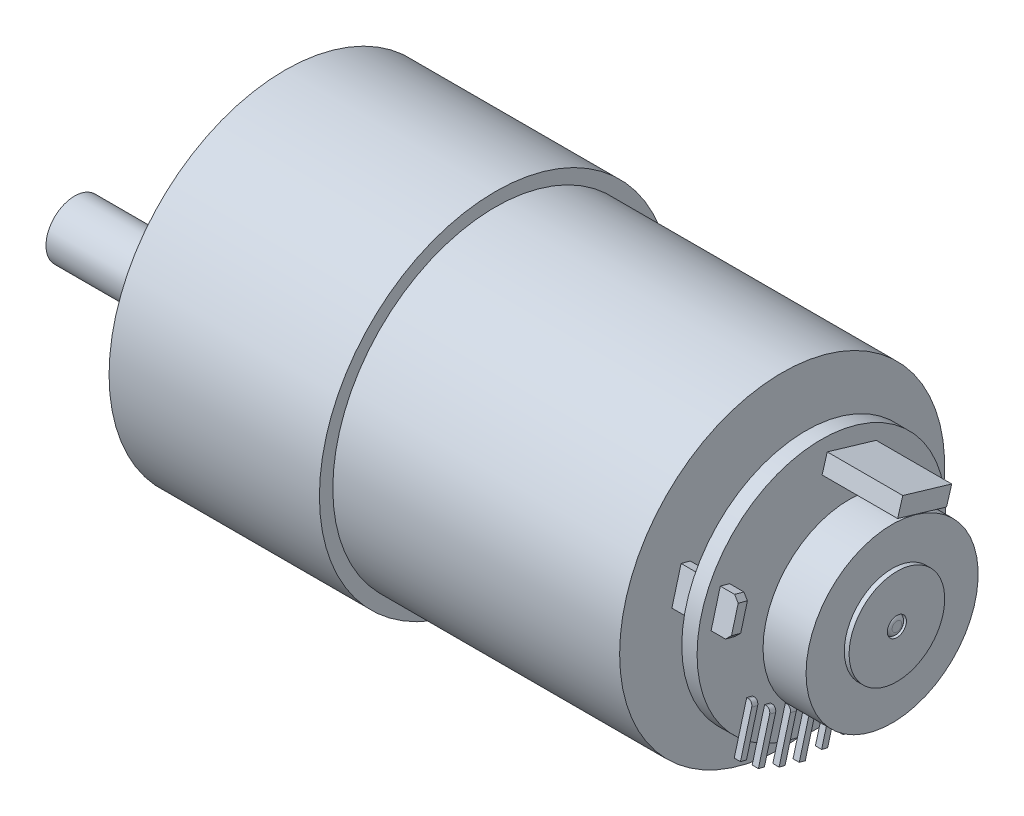
from build123d import *

# Parameters (mm, degrees)
SKETCH2_R           = 6
BOSS_EXTRUDE1_DEPTH = 6.5
SKETCH3_R           = 3
BOSS_EXTRUDE2_DEPTH = 15.5
CUT_EXTRUDE1_DEPTH  = 12
CHAMFER1_SIZE       = 1
SKETCH5_R           = 1.23
CUT_EXTRUDE2_DEPTH  = 5
CIRPATTERN1_COUNT   = 6
BOSS_EXTRUDE3_DEPTH = 7.9
BOSS_EXTRUDE4_DEPTH = 6.1
CHAMFER2_SIZE       = 0.5
BOSS_EXTRUDE5_DEPTH = 0.65
FILLET1_R           = 0.5
CUT_EXTRUDE3_DEPTH  = 1


with BuildPart() as part:
    # Sketch1 → Revolve1 (revolve)
    with BuildSketch(Plane.XY):
        with BuildLine():
            Line((0, 0), (64, 0))
            Line((64, 0), (64, 0.5))
            ThreePointArc((64, 0.5), (63.853553391, 0.853553391), (63.5, 1))
            Line((63.5, 1), (64, 1))
            Line((64, 1), (64, 5))
            Line((64, 5), (63.5, 5))
            Line((63.5, 5), (63.5, 9))
            Line((63.5, 9), (59, 9))
            Line((59, 9), (59, 1))
            Line((59, 1), (56.1, 1))
            Line((56.1, 1), (56.1, 13))
            Line((56.1, 13), (54.5, 13))
            Line((54.5, 13), (54.5, 1))
            Line((54.5, 1), (52, 1))
            Line((52, 1), (52, 17))
            Line((52, 17), (22, 17))
            Line((22, 17), (22, 18.4))
            Line((22, 18.4), (0, 18.4))
            Line((0, 18.4), (0, 0))
        make_face()
    revolve(axis=Axis((0, 0, 0), (1, 0, 0)))

    # Sketch2 → Boss-Extrude1 (add)
    with BuildSketch(Plane.ZY):
        with Locations((0, -7)):
            Circle(SKETCH2_R)
    extrude(amount=BOSS_EXTRUDE1_DEPTH)

    # Sketch3 → Boss-Extrude2 (add)
    with BuildSketch(Plane.ZY.offset(6.5)):
        with Locations((0, -7)):
            Circle(SKETCH3_R)
    extrude(amount=BOSS_EXTRUDE2_DEPTH)

    # Sketch4 → Cut-Extrude1 (cut)
    with BuildSketch(Plane.ZY.offset(22)):
        with BuildLine():
            Line((1.5, -9.598076211), (-1.5, -9.598076211))
            ThreePointArc((-1.5, -9.598076211), (0, -10), (1.5, -9.598076211))
        make_face()
    extrude(amount=-CUT_EXTRUDE1_DEPTH, mode=Mode.SUBTRACT)

    # Chamfer1
    chamfer1_edges = [part.edges().sort_by_distance(p)[0] for p in [
        (-6.5, -7, -6),
    ]]
    chamfer(chamfer1_edges, length=CHAMFER1_SIZE)

    # Sketch5 → Cut-Extrude2 (cut)
    with BuildSketch(Plane.ZY):
        with Locations((15.5, 0)):
            Circle(SKETCH5_R)
    cut_extrude2 = extrude(amount=-CUT_EXTRUDE2_DEPTH, mode=Mode.SUBTRACT)

    # CirPattern1: Cut-Extrude2 ×6 about axis
    cirpattern1_axis = Axis((0, 0, 0), (1, 0, 0))
    for i in range(1, CIRPATTERN1_COUNT):
        add(cut_extrude2.rotate(cirpattern1_axis, i * 360 / CIRPATTERN1_COUNT), mode=Mode.SUBTRACT)

    # Sketch6 → Boss-Extrude3 (add)
    with BuildSketch(Plane(origin=(56.1, 0, 0), x_dir=(0, 0, -1), z_dir=(1, 0, 0))):
        Polygon((0.614545099, 11.559081954), (5.734377326, 10.04515307), (5.196377764, 8.225736367), (0.076545537, 9.739665251), align=None)
    extrude(amount=BOSS_EXTRUDE3_DEPTH)

    # Sketch7 → Boss-Extrude4 (add)
    with BuildSketch(Plane(origin=(52, 0, 0), x_dir=(0, 0, -1), z_dir=(1, 0, 0))):
        Polygon((-10.569640254, 4.993749072), (-11.532445624, 1.431369202), (-10.567082231, 1.170460177), (-9.604276861, 4.732840047), align=None)
        Polygon((10.960206493, -0.825128427), (9.997401123, -4.387508297), (10.962764516, -4.648417322), (11.925569886, -1.086037452), align=None)
    extrude(amount=BOSS_EXTRUDE4_DEPTH)

    # Chamfer2
    chamfer2_edges = [part.edges().sort_by_distance(p)[0] for p in [
        (58.1, 1.300914689, 11.049763927),
        (58.1, 4.86329456, 10.086958557),
        (58.1, -4.51796281, -10.480082819),
        (58.1, -0.955582939, -11.44288819),
    ]]
    chamfer(chamfer2_edges, length=CHAMFER2_SIZE)

    # Sketch9 → Boss-Extrude5 (add)
    with BuildSketch(Plane(origin=(56.1, 0, 0), x_dir=(0, 0, -1), z_dir=(1, 0, 0))):
        Polygon((-7.807702145, -6.480963086), (-9.112247271, -11.307780051), (-8.484761066, -11.477370917), (-7.18021594, -6.650553952), align=None)
        Polygon((-5.932615753, -8.052596911), (-7.237160879, -12.879413876), (-6.609674674, -13.049004742), (-5.305129548, -8.222187777), align=None)
        Polygon((-3.769488931, -8.99589657), (-5.074034056, -13.822713535), (-4.446547851, -13.992304402), (-3.142002725, -9.165487437), align=None)
        Polygon((-1.65786261, -9.621868256), (-2.962407736, -14.448685221), (-2.33492153, -14.618276088), (-1.030376405, -9.791459122), align=None)
        Polygon((0.680101248, -9.624615249), (-0.624443878, -14.451432214), (0.003042327, -14.62102308), (1.307587453, -9.794206115), align=None)
        Polygon((2.920113487, -9.395250912), (1.615568361, -14.222067877), (2.243054567, -14.391658744), (3.547599693, -9.564841778), align=None)
    extrude(amount=BOSS_EXTRUDE5_DEPTH)

    # Fillet1
    fillet1_edges = [part.edges().sort_by_distance(p)[0] for p in [
        (56.75, -6.565758519, 7.493959043),
        (56.75, -8.137392344, 5.618872651),
        (56.75, -9.080692003, 3.455745828),
        (56.75, -9.706663689, 1.344119507),
        (56.75, -9.709410682, -0.99384435),
        (56.75, -9.480046345, -3.23385659),
    ]]
    fillet(fillet1_edges, radius=FILLET1_R)

    # Sketch14 → Cut-Extrude3 (cut)
    with BuildSketch(Plane.ZY):
        with BuildLine():
            ThreePointArc((-9.613871703, -7.181467181), (0, 12), (9.613871703, -7.181467181))
            ThreePointArc((9.613871703, -7.181467181), (8.626247239, -7.502469221), (7.993556247, -6.678972713))
            ThreePointArc((7.993556247, -6.678972713), (0, 1), (-7.993556247, -6.678972713))
            ThreePointArc((-7.993556247, -6.678972713), (-8.626247239, -7.502469221), (-9.613871703, -7.181467181))
        make_face()
    extrude(amount=-CUT_EXTRUDE3_DEPTH, mode=Mode.SUBTRACT)


solid = part.part
